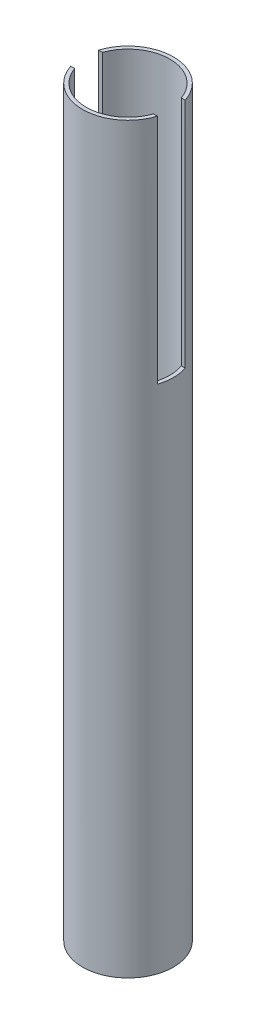
from build123d import *

# Parameters (mm, degrees)
SKETCH1_R           = 21
BOSS_EXTRUDE1_DEPTH = 245
SKETCH2_R           = 24.5
SKETCH2_R_2         = 22.5
BOSS_EXTRUDE2_DEPTH = 400
SKETCH3_W           = 63
SKETCH3_H           = 15
CUT_EXTRUDE1_DEPTH  = 125


with BuildPart() as part:
    # Sketch1 → Boss-Extrude1 (new body)
    with BuildSketch(Plane(origin=(0, 0, 0), x_dir=(1, 0, 0), z_dir=(0, 1, 0))):
        Circle(SKETCH1_R)
    extrude(amount=BOSS_EXTRUDE1_DEPTH)


with BuildPart() as body_2:
    # Sketch2 → Boss-Extrude2 (new body)
    with BuildSketch(Plane(origin=(0, 0, 0), x_dir=(1, 0, 0), z_dir=(0, 1, 0))):
        Circle(SKETCH2_R)
        Circle(SKETCH2_R_2, mode=Mode.SUBTRACT)
    extrude(amount=BOSS_EXTRUDE2_DEPTH)

    # Sketch3 → Cut-Extrude1 (cut)
    with BuildSketch(Plane(origin=(0, 400, 0), x_dir=(1, 0, 0), z_dir=(0, 1, 0))):
        Rectangle(SKETCH3_W, SKETCH3_H)
    extrude(amount=-CUT_EXTRUDE1_DEPTH, mode=Mode.SUBTRACT)


solid = Compound([part.part, body_2.part])
